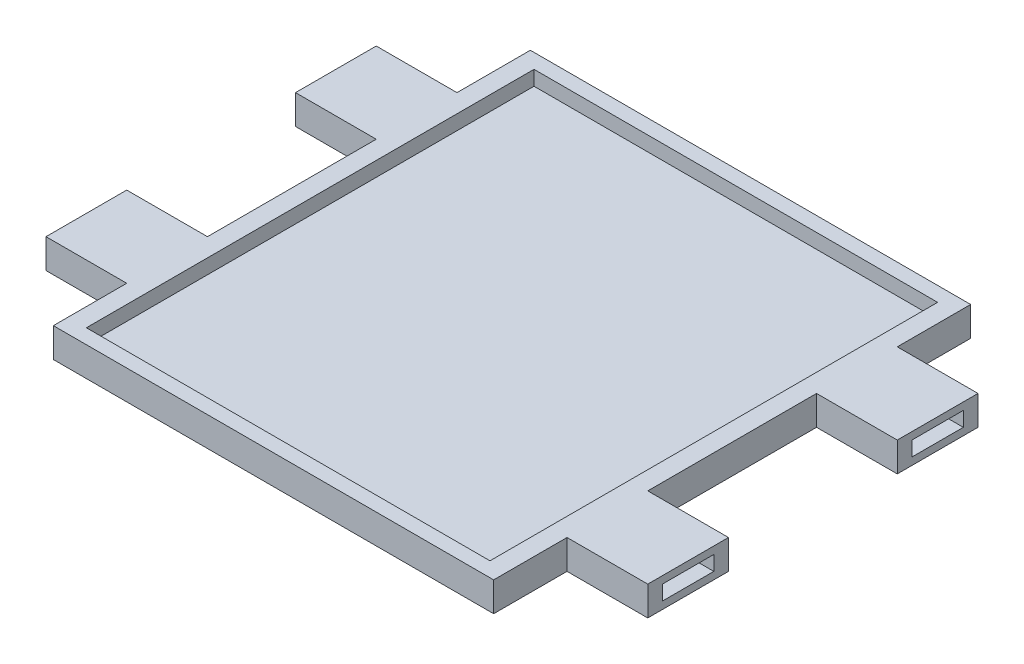
from build123d import *

# Parameters (mm, degrees)
SALIENTE_EXTRUIR1_DEPTH = 4
CROQUIS2_W              = 55
CROQUIS2_H              = 61
CORTAR_EXTRUIR1_DEPTH   = 2
CROQUIS4_W              = 7
CROQUIS4_H              = 2
CORTAR_EXTRUIR2_DEPTH   = 9
CROQUIS6_W              = 7
CROQUIS6_H              = 2
CORTAR_EXTRUIR3_DEPTH   = 9
CROQUIS7_W              = 7
CROQUIS7_H              = 2
CORTAR_EXTRUIR4_DEPTH   = 9
CROQUIS8_W              = 7
CROQUIS8_H              = 2
CORTAR_EXTRUIR5_DEPTH   = 9


with BuildPart() as part:
    # Croquis1 → Saliente-Extruir1 (new body)
    with BuildSketch(Plane(origin=(0, 0, 0), x_dir=(1, 0, 0), z_dir=(0, 1, 0))):
        Polygon((30, -32.5), (30, -22.5), (41, -22.5), (41, -11.5), (30, -11.5), (30, 11.5), (41, 11.5), (41, 22.5), (30, 22.5), (30, 32.5), (-30, 32.5), (-30, 22.5), (-41, 22.5), (-41, 11.5), (-30, 11.5), (-30, -11.5), (-41, -11.5), (-41, -22.5), (-30, -22.5), (-30, -32.5), align=None)
    extrude(amount=SALIENTE_EXTRUIR1_DEPTH)

    # Croquis2 → Cortar-Extruir1 (cut)
    with BuildSketch(Plane(origin=(0, 4, 0), x_dir=(1, 0, 0), z_dir=(0, 1, 0))):
        Rectangle(CROQUIS2_W, CROQUIS2_H)
    extrude(amount=-CORTAR_EXTRUIR1_DEPTH, mode=Mode.SUBTRACT)

    # Croquis4 → Cortar-Extruir2 (cut)
    with BuildSketch(Plane.ZY.offset(41)):
        with Locations((-17, 2)):
            Rectangle(CROQUIS4_W, CROQUIS4_H)
    extrude(amount=-CORTAR_EXTRUIR2_DEPTH, mode=Mode.SUBTRACT)

    # Croquis6 → Cortar-Extruir3 (cut)
    with BuildSketch(Plane.ZY.offset(41)):
        with Locations((17, 2)):
            Rectangle(CROQUIS6_W, CROQUIS6_H)
    extrude(amount=-CORTAR_EXTRUIR3_DEPTH, mode=Mode.SUBTRACT)

    # Croquis7 → Cortar-Extruir4 (cut)
    with BuildSketch(Plane(origin=(41, 0, 0), x_dir=(0, 0, -1), z_dir=(1, 0, 0))):
        with Locations((-17, 2)):
            Rectangle(CROQUIS7_W, CROQUIS7_H)
    extrude(amount=-CORTAR_EXTRUIR4_DEPTH, mode=Mode.SUBTRACT)

    # Croquis8 → Cortar-Extruir5 (cut)
    with BuildSketch(Plane(origin=(41, 0, 0), x_dir=(0, 0, -1), z_dir=(1, 0, 0))):
        with Locations((17, 2)):
            Rectangle(CROQUIS8_W, CROQUIS8_H)
    extrude(amount=-CORTAR_EXTRUIR5_DEPTH, mode=Mode.SUBTRACT)


solid = part.part
